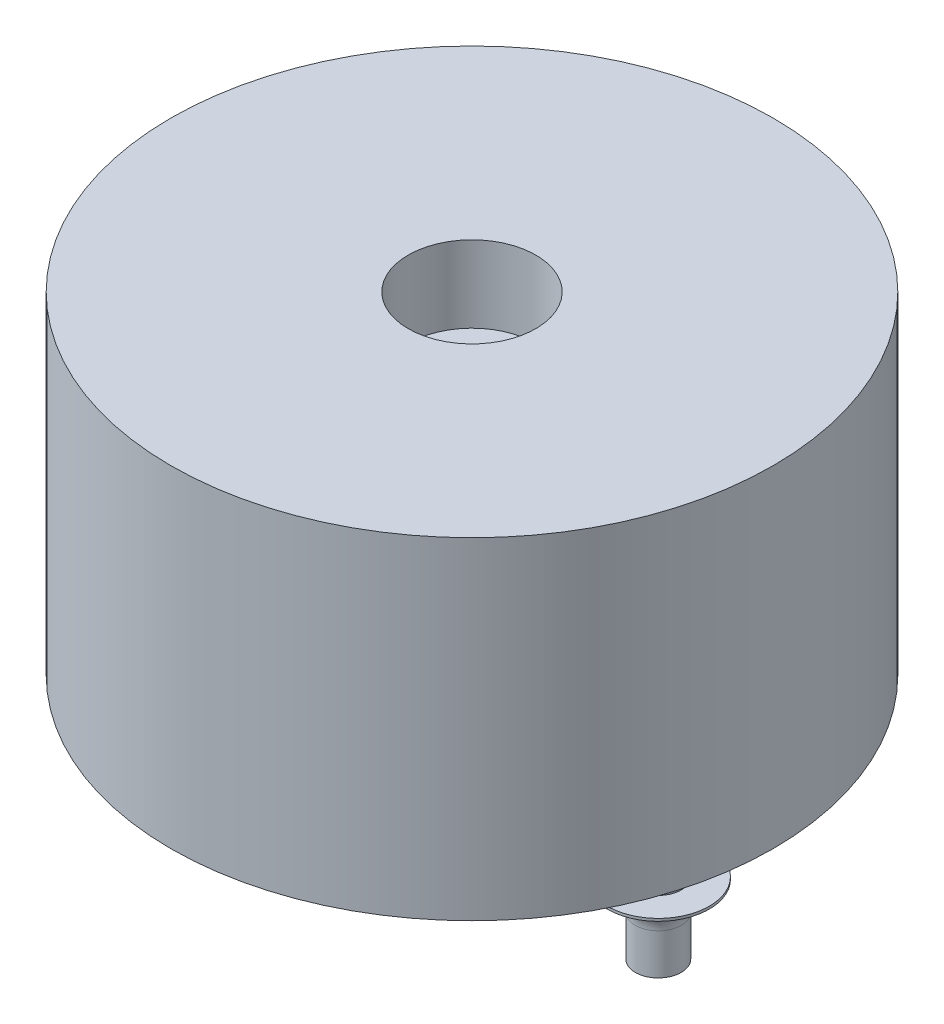
from build123d import *

# Parameters (mm, degrees)
ESQUISSE1_R                = 5.9
BOSS_EXTRU_1_DEPTH         = 6.5
ESQUISSE2_R                = 1.25
ENL_V_MAT_EXTRU_1_DEPTH    = 1.5
R_P_TITION_LIN_AIRE1_COUNT = 2
R_P_TITION_LIN_AIRE1_PITCH = 7.3


with BuildPart() as part:
    # Esquisse1 → Boss.-Extru.1 (new body)
    with BuildSketch(Plane(origin=(0, 0, 0), x_dir=(1, 0, 0), z_dir=(0, 1, 0))):
        Circle(ESQUISSE1_R)
    extrude(amount=BOSS_EXTRU_1_DEPTH)

    # Esquisse2 → Enlèv. mat.-Extru.1 (cut)
    with BuildSketch(Plane(origin=(0, 6.5, 0), x_dir=(1, 0, 0), z_dir=(0, 1, 0))):
        Circle(ESQUISSE2_R)
    extrude(amount=-ENL_V_MAT_EXTRU_1_DEPTH, mode=Mode.SUBTRACT)

    # Esquisse4 → Révolution1 (revolve)
    with BuildSketch(Plane.XY):
        with BuildLine():
            Line((-3.65, -3), (-4.1, -3))
            Line((-4.1, -3), (-4.1, -2.2))
            ThreePointArc((-4.1, -2.2), (-4.26109127, -1.81109127), (-4.65, -1.65))
            Line((-4.65, -1.65), (-4.65, -1.6))
            Line((-4.65, -1.6), (-4.1, -1.6))
            Line((-4.1, -1.6), (-4.1, 0))
            Line((-4.1, 0), (-3.65, 0))
            Line((-3.65, 0), (-3.65, -3))
        make_face()
    r_volution1 = revolve(axis=Axis((-3.65, 0, 0), (0, -1, 0)))

    # Répétition linéaire1: Révolution1 ×2
    with Locations(*[(i * R_P_TITION_LIN_AIRE1_PITCH, 0, 0) for i in range(1, R_P_TITION_LIN_AIRE1_COUNT)]):
        add(r_volution1)


solid = part.part
